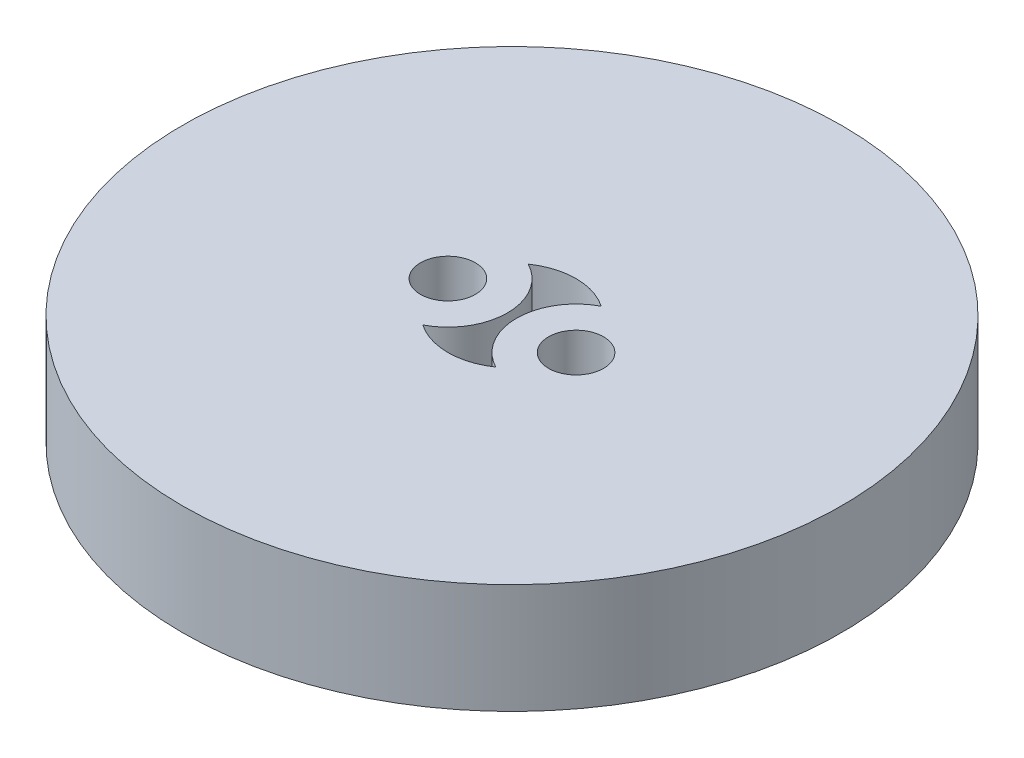
from build123d import *

# Parameters (mm, degrees)
ESQUISSE1_R        = 18
ESQUISSE1_R_2      = 1.5
BOSS_EXTRU_1_DEPTH = 6


with BuildPart() as part:
    # Esquisse1 → Boss.-Extru.1 (new body)
    with BuildSketch(Plane(origin=(0, 0, 0), x_dir=(1, 0, 0), z_dir=(0, 1, 0))):
        Circle(ESQUISSE1_R)
        with Locations((-3.5, 0)):
            Circle(ESQUISSE1_R_2, mode=Mode.SUBTRACT)
        with Locations((3.5, 0)):
            Circle(ESQUISSE1_R_2, mode=Mode.SUBTRACT)
        with BuildLine():
            ThreePointArc((1.991071429, 2.878477821), (0.25, 0), (1.991071429, -2.878477821))
            ThreePointArc((1.991071429, -2.878477821), (0, -3.5), (-1.991071429, -2.878477821))
            ThreePointArc((-1.991071429, -2.878477821), (-0.25, 0), (-1.991071429, 2.878477821))
            ThreePointArc((-1.991071429, 2.878477821), (0, 3.5), (1.991071429, 2.878477821))
        make_face(mode=Mode.SUBTRACT)
    extrude(amount=BOSS_EXTRU_1_DEPTH)


solid = part.part
